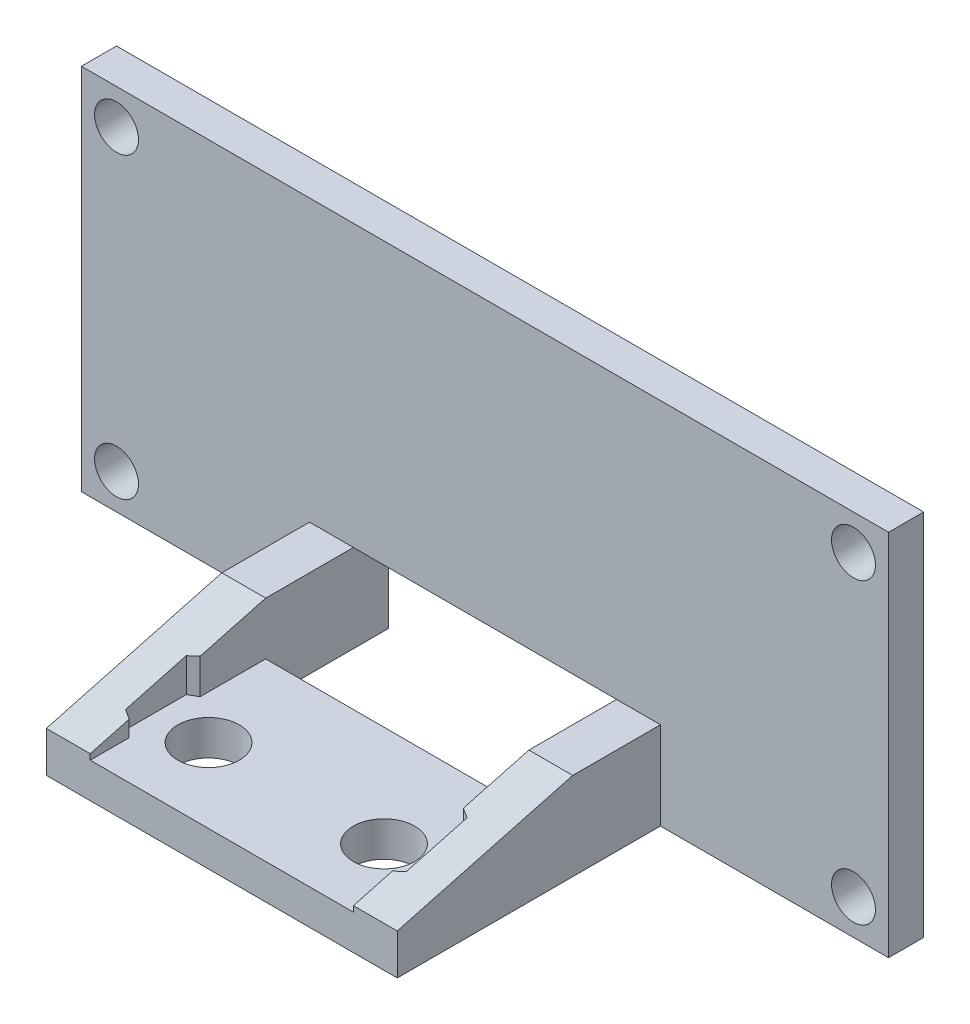
from build123d import *

# Parameters (mm, degrees)
BOSS_EXTRUDE1_DEPTH   = 2
SKETCH2_W             = 2.5
SKETCH2_H             = 5
BOSS_EXTRUDE2_DEPTH   = 15
SKETCH5_W             = 15
SKETCH5_H             = 2
BOSS_EXTRUDE3_DEPTH   = 10
CHAMFER1_SIZE         = 10
CHAMFER1_SIZE2        = 2.679491924
CHAMFER1_PART_2_SIZE  = 10
CHAMFER1_PART_2_SIZE2 = 2.679491924
SKETCH6_R             = 1.25
CUT_EXTRUDE1_DEPTH    = 18
SKETCH7_R             = 1.75
CUT_EXTRUDE2_DEPTH    = 3
CUT_EXTRUDE3_DEPTH    = 20


with BuildPart() as part:
    # Sketch1 → Boss-Extrude1 (new body)
    with BuildSketch(Plane.XY):
        Polygon((23, 10.5), (-23, 10.5), (-23, -10.5), (-7.5, -10.5), (-7.5, -5.5), (7.5, -5.5), (7.5, -10.5), (23, -10.5), align=None)
    extrude(amount=BOSS_EXTRUDE1_DEPTH)

    # Sketch2 → Boss-Extrude2 (add)
    with BuildSketch(Plane.XY.offset(2)):
        with Locations((-8.75, -8)):
            Rectangle(SKETCH2_W, SKETCH2_H)
        with Locations((8.75, -8)):
            Rectangle(SKETCH2_W, SKETCH2_H)
    extrude(amount=BOSS_EXTRUDE2_DEPTH)

    # Sketch5 → Boss-Extrude3 (add)
    with BuildSketch(Plane.XY.offset(17)):
        with Locations((0, -9.5)):
            Rectangle(SKETCH5_W, SKETCH5_H)
    extrude(amount=-BOSS_EXTRUDE3_DEPTH)

    # Chamfer1
    chamfer1_edges = [part.edges().sort_by_distance(p)[0] for p in [
        (-8.75, -5.5, 17),
    ]]
    chamfer1_side = [part.faces().sort_by_distance(p)[0] for p in [
        (-8.75, -5.5, 9.5),
    ]]
    chamfer(chamfer1_edges, length=CHAMFER1_SIZE, length2=CHAMFER1_SIZE2, reference=chamfer1_side[0])

    # Chamfer1 part 2
    chamfer1_part_2_edges = [part.edges().sort_by_distance(p)[0] for p in [
        (8.75, -5.5, 17),
    ]]
    chamfer1_part_2_side = [part.faces().sort_by_distance(p)[0] for p in [
        (8.75, -5.5, 9.5),
    ]]
    chamfer(chamfer1_part_2_edges, length=CHAMFER1_PART_2_SIZE, length2=CHAMFER1_PART_2_SIZE2, reference=chamfer1_part_2_side[0])

    # Sketch6 → Cut-Extrude1 (cut, through all)
    with BuildSketch(Plane(origin=(0, 0, 0), x_dir=(-1, 0, 0), z_dir=(0, 0, -1))):
        with Locations((21, 8.5)):
            Circle(SKETCH6_R)
        with Locations((-21, -8.5)):
            Circle(SKETCH6_R)
        with Locations((-21, 8.5)):
            Circle(SKETCH6_R)
        with Locations((21, -8.5)):
            Circle(SKETCH6_R)
    extrude(amount=-CUT_EXTRUDE1_DEPTH, mode=Mode.SUBTRACT)

    # Sketch7 → Cut-Extrude2 (cut, through all)
    with BuildSketch(Plane(origin=(0, -8.5, 0), x_dir=(1, 0, 0), z_dir=(0, 1, 0))):
        with Locations((-5, -12.755907313)):
            Circle(SKETCH7_R)
        with Locations((5, -12.755907313)):
            Circle(SKETCH7_R)
    extrude(amount=-CUT_EXTRUDE2_DEPTH, mode=Mode.SUBTRACT)

    # Sketch8 → Cut-Extrude3 (cut, through all)
    with BuildSketch(Plane(origin=(0, -8.5, 0), x_dir=(1, 0, 0), z_dir=(0, 1, 0))):
        Polygon((5, -16.220008928), (8, -14.487958121), (8, -11.023856505), (5, -9.291805698), (2, -11.023856505), (2, -14.487958121), align=None)
        Polygon((-5, -16.220008928), (-2, -14.487958121), (-2, -11.023856505), (-5, -9.291805698), (-8, -11.023856505), (-8, -14.487958121), align=None)
    extrude(amount=CUT_EXTRUDE3_DEPTH, mode=Mode.SUBTRACT)


solid = part.part
